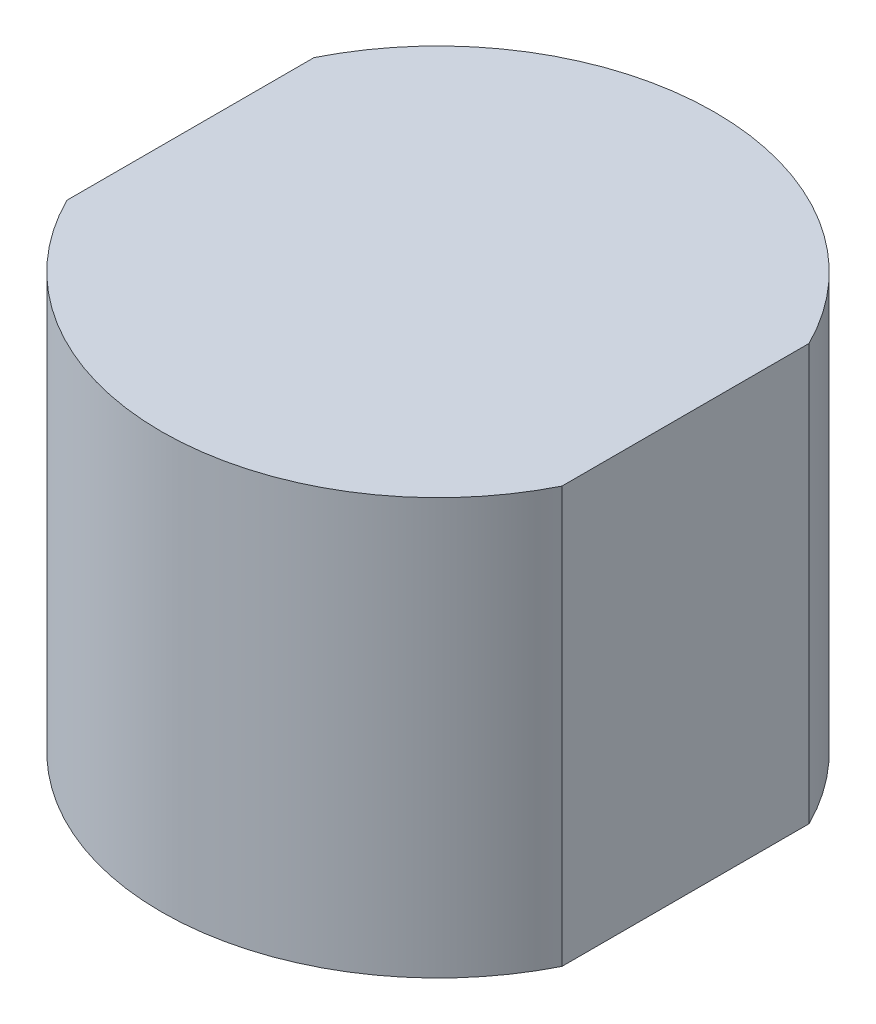
from build123d import *

# Parameters (mm, degrees)
BOSS_EXTRUDE1_DEPTH = 10


with BuildPart() as part:
    # Sketch1 → Boss-Extrude1 (new body)
    with BuildSketch(Plane(origin=(0, 0, 0), x_dir=(1, 0, 0), z_dir=(0, 1, 0))):
        with BuildLine():
            Line((-5.949924369, 2.97), (-5.949924369, -2.97))
            ThreePointArc((-5.949924369, -2.97), (0, -6.65), (5.949924369, -2.97))
            Line((5.949924369, -2.97), (5.949924369, 2.97))
            ThreePointArc((5.949924369, 2.97), (0, 6.65), (-5.949924369, 2.97))
        make_face()
    extrude(amount=BOSS_EXTRUDE1_DEPTH)


solid = part.part
